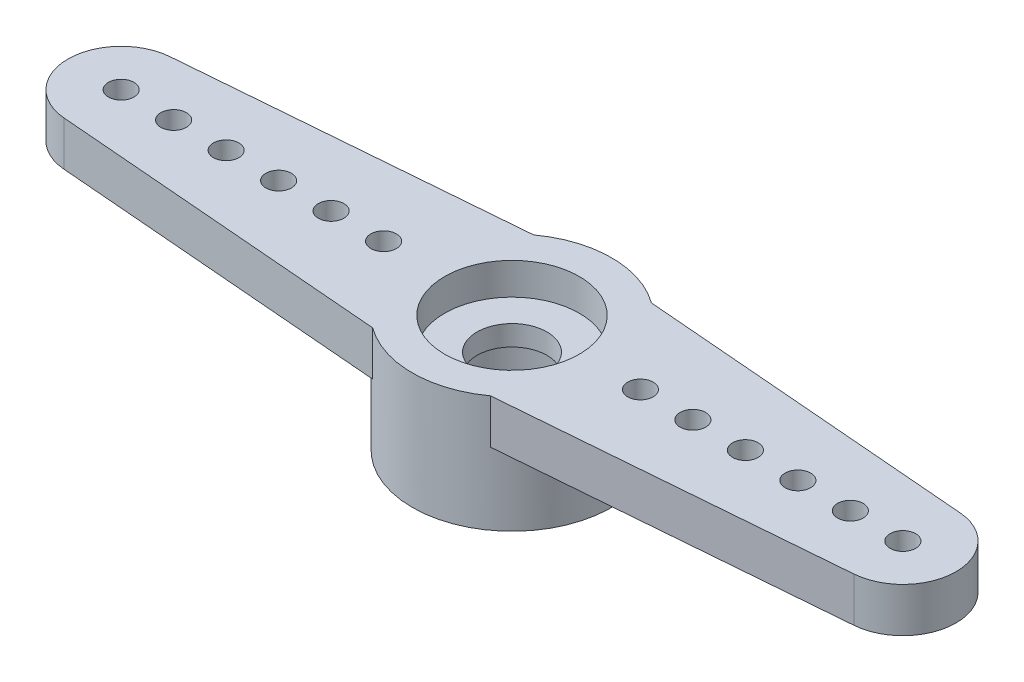
from build123d import *

# Parameters (mm, degrees)
EXTRUDE17_DEPTH = 1.6129
SKETCH19_R      = 3.6195
EXTRUDE19_DEPTH = 4.2291
SKETCH20_R      = 0.46355
SKETCH20_R_2    = 1.27
EXTRUDE20_DEPTH = 5.2291
SKETCH21_R      = 2.44475
EXTRUDE21_DEPTH = 1.1557
SKETCH22_R      = 2.286
EXTRUDE22_DEPTH = 2.3368


with BuildPart() as part:
    # Sketch18 → Extrude17 (new body)
    with BuildSketch(Plane(origin=(0, 0, 0), x_dir=(1, 0, 0), z_dir=(0, 1, 0))):
        with BuildLine():
            Line((-14.34305969, 1.923991942), (-2.13741415, 2.921))
            ThreePointArc((-2.13741415, 2.921), (0, 3.6195), (2.13741415, 2.921))
            Line((2.13741415, 2.921), (14.34305969, 1.923991942))
            ThreePointArc((14.34305969, 1.923991942), (16.1163, 0), (14.34305969, -1.923991942))
            Line((14.34305969, -1.923991942), (2.13741415, -2.921))
            ThreePointArc((2.13741415, -2.921), (0, -3.6195), (-2.13741415, -2.921))
            Line((-2.13741415, -2.921), (-14.34305969, -1.923991942))
            ThreePointArc((-14.34305969, -1.923991942), (-16.1163, 0), (-14.34305969, 1.923991942))
        make_face()
    extrude(amount=EXTRUDE17_DEPTH)

    # Sketch19 → Extrude19 (add)
    with BuildSketch(Plane(origin=(0, 1.6129, 0), x_dir=(1, 0, 0), z_dir=(0, 1, 0))):
        Circle(SKETCH19_R)
    extrude(amount=-EXTRUDE19_DEPTH)

    # Sketch20 → Extrude20 (cut, through all)
    with BuildSketch(Plane(origin=(0, 1.6129, 0), x_dir=(1, 0, 0), z_dir=(0, 1, 0))):
        with Locations((-14.1859, 0)):
            Circle(SKETCH20_R)
        Circle(SKETCH20_R_2)
        with Locations((-4.6609, 0)):
            Circle(SKETCH20_R)
        with Locations((-6.5659, 0)):
            Circle(SKETCH20_R)
        with Locations((-8.4709, 0)):
            Circle(SKETCH20_R)
        with Locations((-10.3759, 0)):
            Circle(SKETCH20_R)
        with Locations((-12.2809, 0)):
            Circle(SKETCH20_R)
    extrude20 = extrude(amount=-EXTRUDE20_DEPTH, mode=Mode.SUBTRACT)

    # Mirror1: Extrude20 across plane
    add(extrude20.mirror(Plane(origin=(0, 0, 0), x_dir=(0, 0, 1), z_dir=(1, 0, 0))), mode=Mode.SUBTRACT)

    # Sketch21 → Extrude21 (cut)
    with BuildSketch(Plane(origin=(0, 1.6129, 0), x_dir=(1, 0, 0), z_dir=(0, 1, 0))):
        Circle(SKETCH21_R)
    extrude(amount=-EXTRUDE21_DEPTH, mode=Mode.SUBTRACT)

    # Sketch22 → Extrude22 (cut)
    with BuildSketch(Plane.XZ.offset(2.6162)):
        Circle(SKETCH22_R)
    extrude(amount=-EXTRUDE22_DEPTH, mode=Mode.SUBTRACT)


solid = part.part
